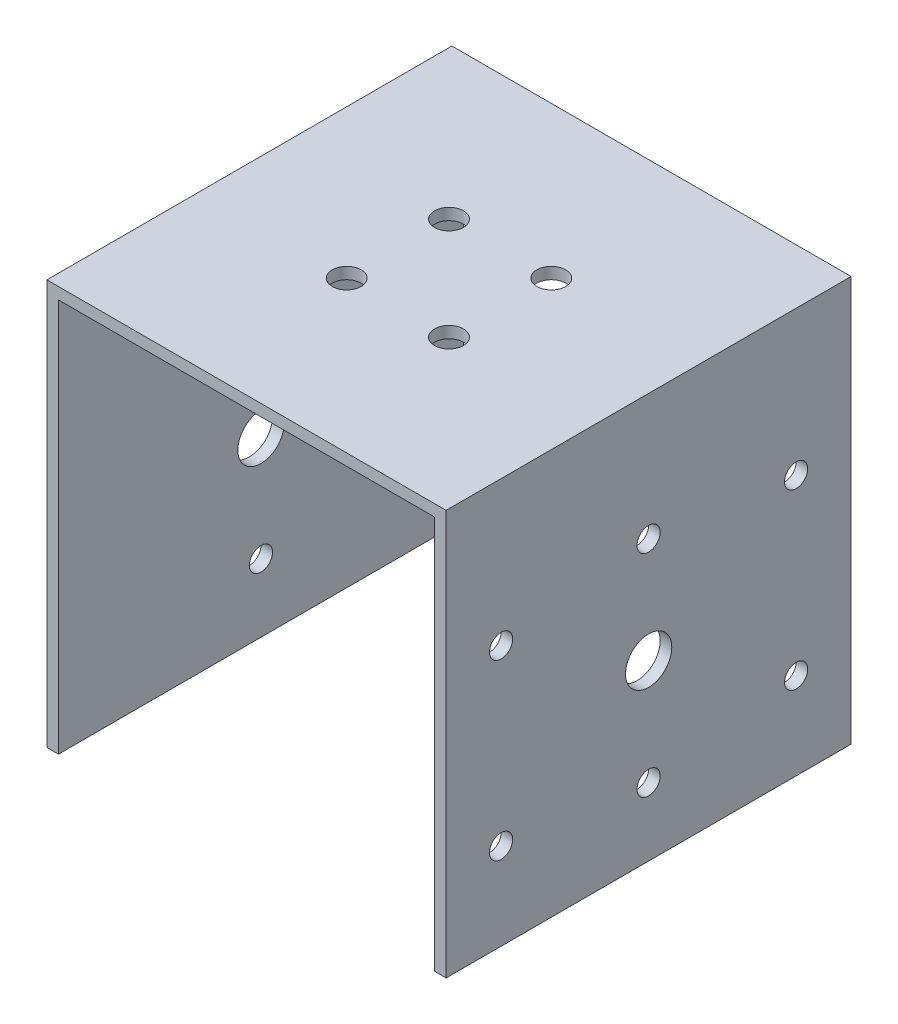
from build123d import *

# Parameters (mm, degrees)
RESSALTO_EXTRUS_O1_DEPTH = 60
ESBO_O2_R                = 4
CORTE_EXTRUS_O1_DEPTH    = 65
ESBO_O3_R                = 2.5
CORTE_EXTRUS_O2_DEPTH    = 10
RESSALTO_EXTRUS_O2_DEPTH = 5
RESSALTO_EXTRUS_O3_DEPTH = 5
ESBO_O6_R                = 2
CORTE_EXTRUS_O3_DEPTH    = 10
ESBO_O7_W                = 70
ESBO_O7_H                = 70
ESBO_O7_R                = 2
ESBO_O7_R_2              = 4
RESSALTO_EXTRUS_O4_DEPTH = 2.5
ESBO_O8_W                = 70
ESBO_O8_H                = 70
ESBO_O8_R                = 4
RESSALTO_EXTRUS_O5_DEPTH = 2.5
ESBO_O9_W                = 70
ESBO_O9_H                = 68
CORTE_EXTRUS_O4_DEPTH    = 2.5
ESBO_O10_W               = 70
ESBO_O10_H               = 68
CORTE_EXTRUS_O5_DEPTH    = 2.5
ESBO_O11_R               = 2
CORTE_EXTRUS_O6_DEPTH    = 70


with BuildPart() as part:
    # Esboço1 → Ressalto-extrusão1 (new body)
    with BuildSketch(Plane.XY):
        Polygon((32, -15), (32, 55), (-32, 55), (-32, -15), (-30, -15), (-30, -13), (-30, 53), (30, 53), (30, -13), (30, -15), align=None)
    extrude(amount=RESSALTO_EXTRUS_O1_DEPTH)

    # Esboço2 → Corte-extrusão1 (cut, through all)
    with BuildSketch(Plane(origin=(32, 0, 0), x_dir=(0, 0, -1), z_dir=(1, 0, 0))):
        with Locations((-30, 15)):
            Circle(ESBO_O2_R)
    extrude(amount=-CORTE_EXTRUS_O1_DEPTH, mode=Mode.SUBTRACT)

    # Esboço3 → Corte-extrusão2 (cut)
    with BuildSketch(Plane.XZ.offset(-53)):
        with Locations((-8.838834765, 38.838834765)):
            Circle(ESBO_O3_R)
        with Locations((-8.838834765, 21.161165235)):
            Circle(ESBO_O3_R)
        with Locations((8.838834765, 21.161165235)):
            Circle(ESBO_O3_R)
        with Locations((8.838834765, 38.838834765)):
            Circle(ESBO_O3_R)
    extrude(amount=-CORTE_EXTRUS_O2_DEPTH, mode=Mode.SUBTRACT)

    # Esboço4 → Ressalto-extrusão2 (add)
    with BuildSketch(Plane.XY.offset(60)):
        Polygon((-32, 55), (-32, -15), (-30, -15), (-30, 53), (30, 53), (30, -15), (32, -15), (32, 55), align=None)
    extrude(amount=RESSALTO_EXTRUS_O2_DEPTH)

    # Esboço5 → Ressalto-extrusão3 (add)
    with BuildSketch(Plane(origin=(0, 0, 0), x_dir=(-1, 0, 0), z_dir=(0, 0, -1))):
        Polygon((32, -15), (32, 55), (-32, 55), (-32, -15), (-30, -15), (-30, 53), (30, 53), (30, -15), align=None)
    extrude(amount=RESSALTO_EXTRUS_O3_DEPTH)

    # Esboço6 → Corte-extrusão3 (cut)
    with BuildSketch(Plane(origin=(32, 0, 0), x_dir=(0, 0, -1), z_dir=(1, 0, 0))):
        with Locations((-4.5, 0)):
            Circle(ESBO_O6_R)
        with Locations((-4.5, 30)):
            Circle(ESBO_O6_R)
        with Locations((-55.5, 0)):
            Circle(ESBO_O6_R)
        with Locations((-55.5, 30)):
            Circle(ESBO_O6_R)
    extrude(amount=-CORTE_EXTRUS_O3_DEPTH, mode=Mode.SUBTRACT)

    # Esboço7 → Ressalto-extrusão4 (add)
    with BuildSketch(Plane(origin=(32, 0, 0), x_dir=(0, 0, -1), z_dir=(1, 0, 0))):
        with Locations((-30, 20)):
            Rectangle(ESBO_O7_W, ESBO_O7_H)
        with Locations((-55.5, 0)):
            Circle(ESBO_O7_R, mode=Mode.SUBTRACT)
        with Locations((-55.5, 30)):
            Circle(ESBO_O7_R, mode=Mode.SUBTRACT)
        with Locations((-30, 15)):
            Circle(ESBO_O7_R_2, mode=Mode.SUBTRACT)
        with Locations((-4.5, 0)):
            Circle(ESBO_O7_R, mode=Mode.SUBTRACT)
        with Locations((-4.5, 30)):
            Circle(ESBO_O7_R, mode=Mode.SUBTRACT)
    extrude(amount=RESSALTO_EXTRUS_O4_DEPTH)

    # Esboço8 → Ressalto-extrusão5 (add)
    with BuildSketch(Plane.ZY.offset(32)):
        with Locations((30, 20)):
            Rectangle(ESBO_O8_W, ESBO_O8_H)
        with Locations((30, 15)):
            Circle(ESBO_O8_R, mode=Mode.SUBTRACT)
    extrude(amount=RESSALTO_EXTRUS_O5_DEPTH)

    # Esboço9 → Corte-extrusão4 (cut)
    with BuildSketch(Plane.ZY.offset(-30)):
        with Locations((30, 19)):
            Rectangle(ESBO_O9_W, ESBO_O9_H)
    extrude(amount=-CORTE_EXTRUS_O4_DEPTH, mode=Mode.SUBTRACT)

    # Esboço10 → Corte-extrusão5 (cut)
    with BuildSketch(Plane(origin=(-30, 0, 0), x_dir=(0, 0, -1), z_dir=(1, 0, 0))):
        with Locations((-30, 19)):
            Rectangle(ESBO_O10_W, ESBO_O10_H)
    extrude(amount=-CORTE_EXTRUS_O5_DEPTH, mode=Mode.SUBTRACT)

    # Esboço11 → Corte-extrusão6 (cut, through all)
    with BuildSketch(Plane(origin=(34.5, 0, 0), x_dir=(0, 0, -1), z_dir=(1, 0, 0))):
        with Locations((-30, -3.25)):
            Circle(ESBO_O11_R)
        with Locations((-30, 33.25)):
            Circle(ESBO_O11_R)
    extrude(amount=-CORTE_EXTRUS_O6_DEPTH, mode=Mode.SUBTRACT)


solid = part.part
